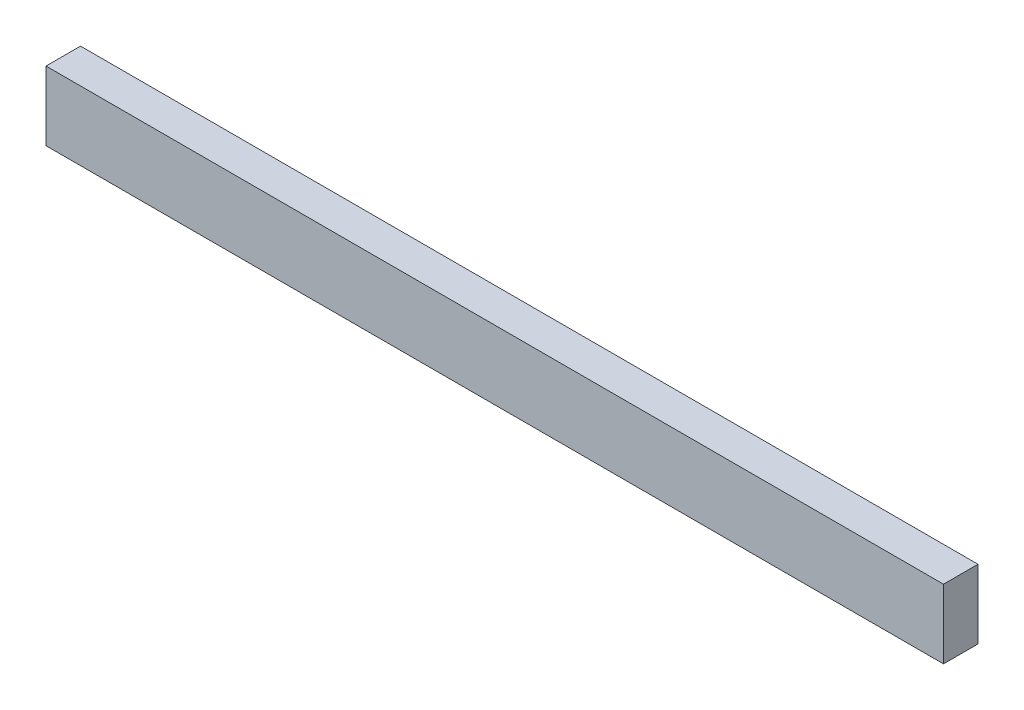
from build123d import *

# Parameters (mm, degrees)
SKETCH1_W           = 260
SKETCH1_H           = 10
BOSS_EXTRUDE1_DEPTH = 20


with BuildPart() as part:
    # Sketch1 → Boss-Extrude1 (new body)
    with BuildSketch(Plane(origin=(0, 0, 0), x_dir=(1, 0, 0), z_dir=(0, 1, 0))):
        with Locations((-9.035099735, -37.99122807)):
            Rectangle(SKETCH1_W, SKETCH1_H)
    extrude(amount=BOSS_EXTRUDE1_DEPTH)


solid = part.part
